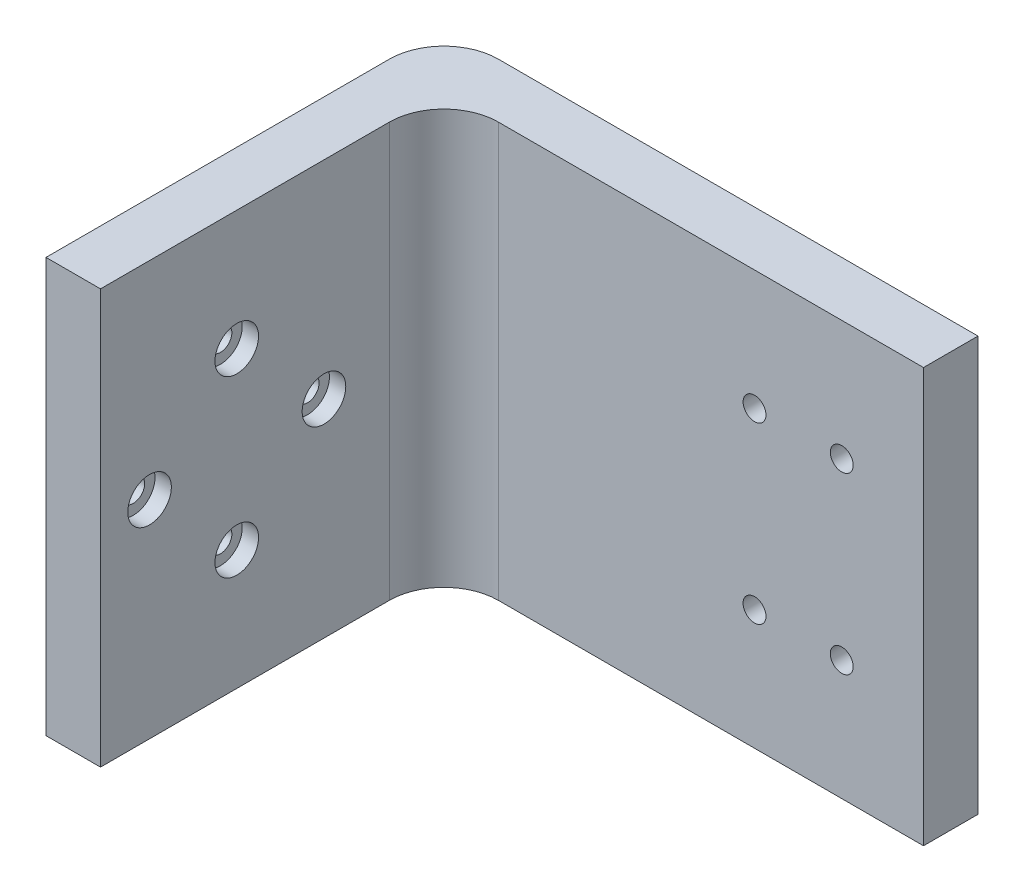
from build123d import *

# Parameters (mm, degrees)
SKETCH1_W           = 31.5
SKETCH1_H           = 38
BOSS_EXTRUDE1_DEPTH = 5
SKETCH3_W           = 64
SKETCH3_H           = 38
BOSS_EXTRUDE3_DEPTH = 5
SKETCH7_R           = 1.05
CUT_EXTRUDE3_DEPTH  = 5
SKETCH8_W           = 10
SKETCH8_H           = 38
CUT_EXTRUDE4_DEPTH  = 10
FILLET1_R           = 5
SKETCH9_R           = 2
CUT_EXTRUDE5_DEPTH  = 1.5
SKETCH11_R          = 2
CUT_EXTRUDE7_DEPTH  = 1.5
CUT_EXTRUDE8_DEPTH  = 39


with BuildPart() as part:
    # Sketch1 → Boss-Extrude1 (new body)
    with BuildSketch(Plane(origin=(0, 0, 0), x_dir=(0, 0, -1), z_dir=(1, 0, 0))):
        with Locations((3.25, 0)):
            Rectangle(SKETCH1_W, SKETCH1_H)
        with BuildLine():
            ThreePointArc((1.05, 8), (0, 9.05), (-1.05, 8))
            ThreePointArc((-1.05, 8), (0, 6.95), (1.05, 8))
        make_face(mode=Mode.SUBTRACT)
        with BuildLine():
            ThreePointArc((6.95, 0), (8, -1.05), (9.05, 0))
            ThreePointArc((9.05, 0), (8, 1.05), (6.95, 0))
        make_face(mode=Mode.SUBTRACT)
        with BuildLine():
            ThreePointArc((-1.05, -8), (0, -9.05), (1.05, -8))
            ThreePointArc((1.05, -8), (0, -6.95), (-1.05, -8))
        make_face(mode=Mode.SUBTRACT)
        with BuildLine():
            ThreePointArc((-9.05, 0), (-8, -1.05), (-6.95, 0))
            ThreePointArc((-6.95, 0), (-8, 1.05), (-9.05, 0))
        make_face(mode=Mode.SUBTRACT)
    extrude(amount=BOSS_EXTRUDE1_DEPTH)

    # Sketch3 → Boss-Extrude3 (add)
    with BuildSketch(Plane(origin=(0, 0, -19), x_dir=(-1, 0, 0), z_dir=(0, 0, -1))):
        with Locations((-32, 0)):
            Rectangle(SKETCH3_W, SKETCH3_H)
    extrude(amount=BOSS_EXTRUDE3_DEPTH)

    # Sketch7 → Cut-Extrude3 (cut)
    with BuildSketch(Plane.XY.offset(-19)):
        with Locations((33.5, 8)):
            Circle(SKETCH7_R)
        with Locations((33.5, -8)):
            Circle(SKETCH7_R)
        with BuildLine():
            ThreePointArc((41.5, -6.95), (40.45, -8), (41.5, -9.05))
            ThreePointArc((41.5, -9.05), (42.55, -8), (41.5, -6.95))
        make_face()
        with BuildLine():
            ThreePointArc((41.5, 9.05), (40.45, 8), (41.5, 6.95))
            ThreePointArc((41.5, 6.95), (42.55, 8), (41.5, 9.05))
        make_face()
    extrude(amount=-CUT_EXTRUDE3_DEPTH, mode=Mode.SUBTRACT)

    # Sketch8 → Cut-Extrude4 (cut)
    with BuildSketch(Plane(origin=(0, 0, -24), x_dir=(-1, 0, 0), z_dir=(0, 0, -1))):
        with Locations((-59, 0)):
            Rectangle(SKETCH8_W, SKETCH8_H)
    extrude(amount=-CUT_EXTRUDE4_DEPTH, mode=Mode.SUBTRACT)

    # Fillet1
    fillet1_edges = [part.edges().sort_by_distance(p)[0] for p in [
        (0, 0, -24),
        (5, 0, -19),
    ]]
    fillet(fillet1_edges, radius=FILLET1_R)

    # Sketch9 → Cut-Extrude5 (cut)
    with BuildSketch(Plane(origin=(0, 0, -24), x_dir=(-1, 0, 0), z_dir=(0, 0, -1))):
        with Locations((-41.5, 8)):
            Circle(SKETCH9_R)
        with Locations((-41.5, -8)):
            Circle(SKETCH9_R)
        with Locations((-33.5, 8)):
            Circle(SKETCH9_R)
        with Locations((-33.5, -8)):
            Circle(SKETCH9_R)
    extrude(amount=-CUT_EXTRUDE5_DEPTH, mode=Mode.SUBTRACT)

    # Sketch11 → Cut-Extrude7 (cut)
    with BuildSketch(Plane(origin=(5, 0, 0), x_dir=(0, 0, -1), z_dir=(1, 0, 0))):
        with Locations((0, 8)):
            Circle(SKETCH11_R)
        with Locations((-8, 0)):
            Circle(SKETCH11_R)
        with Locations((0, -8)):
            Circle(SKETCH11_R)
        with Locations((8, 0)):
            Circle(SKETCH11_R)
    extrude(amount=-CUT_EXTRUDE7_DEPTH, mode=Mode.SUBTRACT)

    # Sketch12 → Cut-Extrude8 (cut, through all)
    with BuildSketch(Plane(origin=(0, 19, 0), x_dir=(1, 0, 0), z_dir=(0, 1, 0))):
        Polygon((54, 24), (49, 24), (49, 17.432960287), (56.636110038, 15.929403626), (56.327583627, 23.530489308), align=None)
    extrude(amount=-CUT_EXTRUDE8_DEPTH, mode=Mode.SUBTRACT)


solid = part.part
